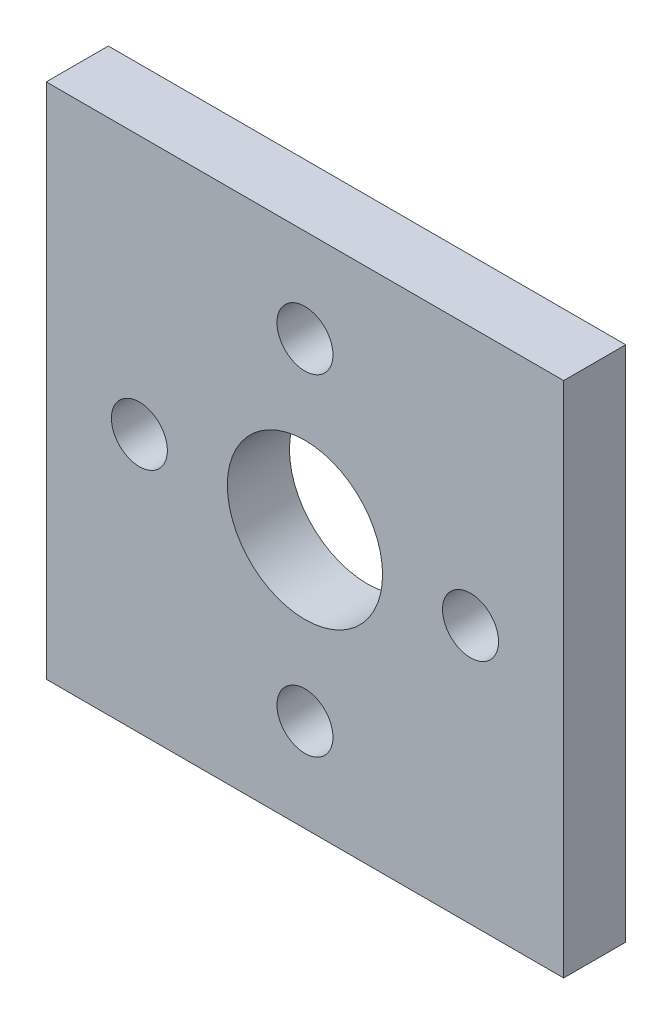
from build123d import *

# Parameters (mm, degrees)
SKETCH1_W           = 25
SKETCH1_H           = 25
SKETCH1_R           = 3.75
SKETCH1_R_2         = 1.35255
BOSS_EXTRUDE1_DEPTH = 3


with BuildPart() as part:
    # Sketch1 → Boss-Extrude1 (new body)
    with BuildSketch(Plane.XY):
        Rectangle(SKETCH1_W, SKETCH1_H)
        Circle(SKETCH1_R, mode=Mode.SUBTRACT)
        with Locations((0, 8)):
            Circle(SKETCH1_R_2, mode=Mode.SUBTRACT)
        with Locations((0, -8)):
            Circle(SKETCH1_R_2, mode=Mode.SUBTRACT)
        with Locations((8, 0)):
            Circle(SKETCH1_R_2, mode=Mode.SUBTRACT)
        with Locations((-8, 0)):
            Circle(SKETCH1_R_2, mode=Mode.SUBTRACT)
    extrude(amount=BOSS_EXTRUDE1_DEPTH)


solid = part.part
